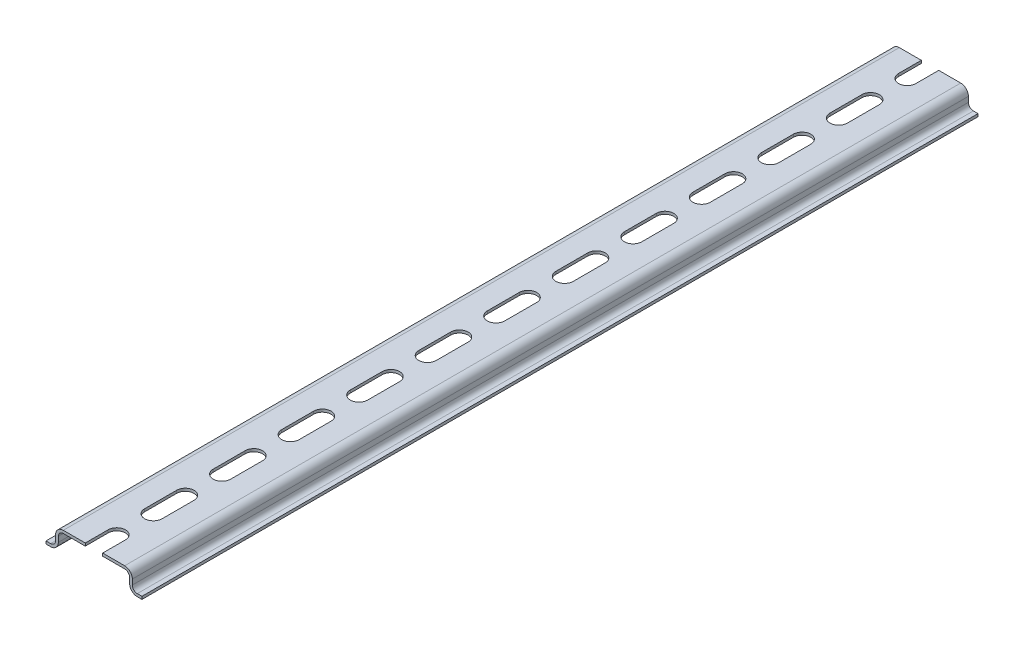
from build123d import *

# Parameters (mm, degrees)
EXTRUDE_MAIN_DEPTH     = 152.5
SLOT_CUT_DEPTH         = 8.5
SLOT_PATTERN_COUNT     = 7
SLOT_PATTERN_PITCH     = 25
SLOT_PATTERN_COL_COUNT = 7
SLOT_PATTERN_COL_PITCH = 25


with BuildPart() as part:
    # Sketch1 → Extrude_main (new body, symmetric)
    with BuildSketch(Plane.XY):
        with BuildLine():
            Line((-17.5, 0), (-15.8, 0))
            ThreePointArc((-15.8, 0), (-13.820101013, 0.820101013), (-13, 2.8))
            Line((-13, 2.8), (-13, 4.7))
            ThreePointArc((-13, 4.7), (-12.472792206, 5.972792206), (-11.2, 6.5))
            Line((-11.2, 6.5), (11.2, 6.5))
            ThreePointArc((11.2, 6.5), (12.472792206, 5.972792206), (13, 4.7))
            Line((13, 4.7), (13, 2.8))
            ThreePointArc((13, 2.8), (13.820101013, 0.820101013), (15.8, 0))
            Line((15.8, 0), (17.5, 0))
            Line((17.5, 0), (17.5, 1))
            Line((17.5, 1), (15.8, 1))
            ThreePointArc((15.8, 1), (14.527207794, 1.527207794), (14, 2.8))
            Line((14, 2.8), (14, 4.7))
            ThreePointArc((14, 4.7), (13.179898987, 6.679898987), (11.2, 7.5))
            Line((11.2, 7.5), (-11.2, 7.5))
            ThreePointArc((-11.2, 7.5), (-13.179898987, 6.679898987), (-14, 4.7))
            Line((-14, 4.7), (-14, 2.8))
            ThreePointArc((-14, 2.8), (-14.527207794, 1.527207794), (-15.8, 1))
            Line((-15.8, 1), (-17.5, 1))
            Line((-17.5, 1), (-17.5, 0))
        make_face()
    extrude(amount=EXTRUDE_MAIN_DEPTH, both=True)

    # Sketch2 → slot_cut (cut, through all)
    with BuildSketch(Plane(origin=(0, 0, 0), x_dir=(1, 0, 0), z_dir=(0, 1, 0))):
        with BuildLine():
            Line((-3.175, 5.825), (-3.175, -5.825))
            ThreePointArc((-3.175, -5.825), (0, -9), (3.175, -5.825))
            Line((3.175, -5.825), (3.175, 5.825))
            ThreePointArc((3.175, 5.825), (0, 9), (-3.175, 5.825))
        make_face()
    slot_cut = extrude(amount=SLOT_CUT_DEPTH, mode=Mode.SUBTRACT)

    # slot_pattern: slot_cut ×7
    with Locations(*[(0, 0, i * SLOT_PATTERN_PITCH) for i in range(1, SLOT_PATTERN_COUNT)]):
        add(slot_cut, mode=Mode.SUBTRACT)

    # slot_pattern col: slot_cut ×7
    with Locations(*[(0, 0, -i * SLOT_PATTERN_COL_PITCH) for i in range(1, SLOT_PATTERN_COL_COUNT)]):
        add(slot_cut, mode=Mode.SUBTRACT)


solid = part.part
